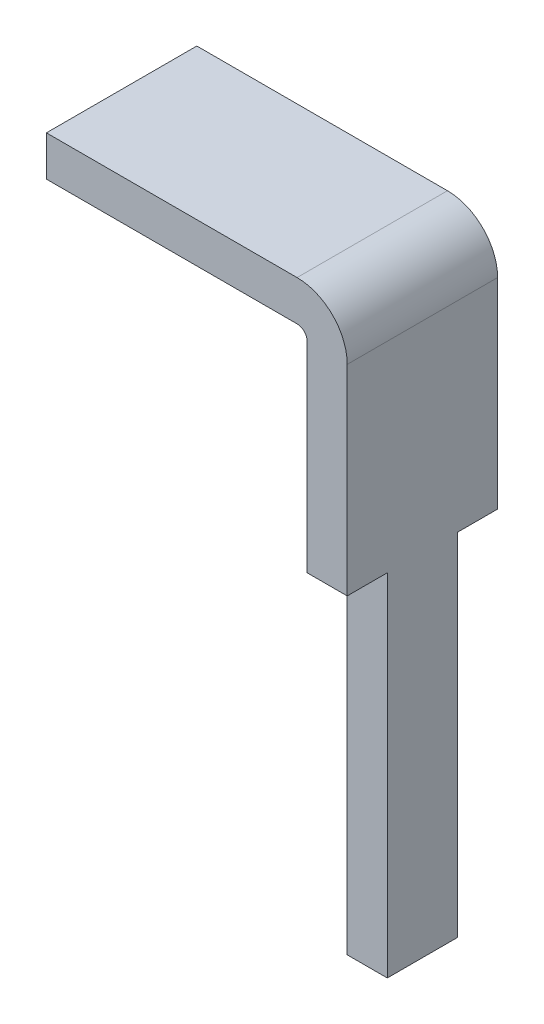
from build123d import *

# Parameters (mm, degrees)
BOSS_EXTRUDE1_DEPTH = 1.5
CUT_EXTRUDE1_REACH  = 5
SKETCH2_W           = 0.4
SKETCH2_H           = 3.5


with BuildPart() as part:
    # Sketch1 → Boss-Extrude1 (new body)
    with BuildSketch(Plane.XY):
        with BuildLine():
            Line((0, 0), (2.5, 0))
            ThreePointArc((2.5, 0), (2.853553391, -0.146446609), (3, -0.5))
            Line((3, -0.5), (3, -6))
            Line((3, -6), (2.6, -6))
            Line((2.6, -6), (2.6, -0.5))
            ThreePointArc((2.6, -0.5), (2.570710678, -0.429289322), (2.5, -0.4))
            Line((2.5, -0.4), (0, -0.4))
            Line((0, -0.4), (0, 0))
        make_face()
    extrude(amount=BOSS_EXTRUDE1_DEPTH)

    # Sketch2 → Cut-Extrude1 (cut, up to next)
    with BuildSketch(Plane(origin=(3, 0, 0), x_dir=(0, 0, -1), z_dir=(1, 0, 0)), mode=Mode.PRIVATE) as cut_extrude1_sk1:
        with Locations((-0.2, -4.25)):
            Rectangle(SKETCH2_W, SKETCH2_H)
    cut_extrude1_tool1 = extrude(cut_extrude1_sk1.sketch, amount=-CUT_EXTRUDE1_REACH, mode=Mode.PRIVATE) & part.part
    add(cut_extrude1_tool1.solids().sort_by_distance((3, -4.25, 0.2))[0], mode=Mode.SUBTRACT)
    # Sketch2 → Cut-Extrude1 (cut, up to next)
    with BuildSketch(Plane(origin=(3, 0, 0), x_dir=(0, 0, -1), z_dir=(1, 0, 0)), mode=Mode.PRIVATE) as cut_extrude1_sk2:
        with Locations((-1.3, -4.25)):
            Rectangle(SKETCH2_W, SKETCH2_H)
    cut_extrude1_tool2 = extrude(cut_extrude1_sk2.sketch, amount=-CUT_EXTRUDE1_REACH, mode=Mode.PRIVATE) & part.part
    add(cut_extrude1_tool2.solids().sort_by_distance((3, -4.25, 1.3))[0], mode=Mode.SUBTRACT)


solid = part.part
